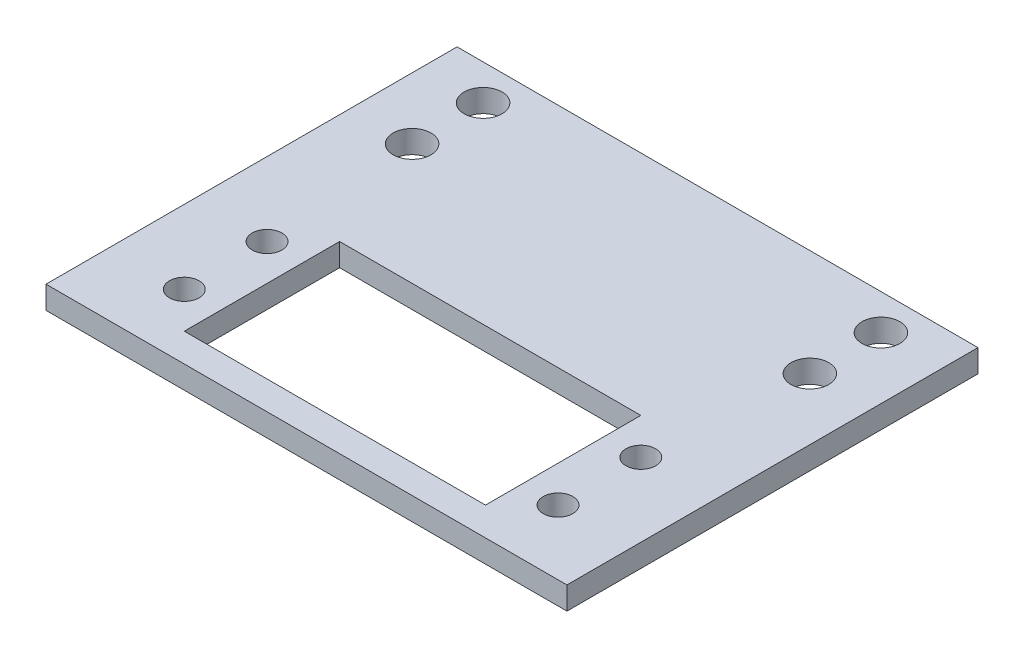
from build123d import *

# Parameters (mm, degrees)
SKETCH1_W           = 69.85
SKETCH1_H           = 55.118
SKETCH1_R           = 1.98755
SKETCH1_R_2         = 2.54
SKETCH1_W_2         = 40.386
SKETCH1_H_2         = 20.828
BOSS_EXTRUDE1_DEPTH = 3.048


with BuildPart() as part:
    # Sketch1 → Boss-Extrude1 (new body)
    with BuildSketch(Plane(origin=(0, 0, 0), x_dir=(1, 0, 0), z_dir=(0, 1, 0))):
        with Locations((0, 13.335)):
            Rectangle(SKETCH1_W, SKETCH1_H)
        with Locations((-25.0571, -5.5499)):
            Circle(SKETCH1_R, mode=Mode.SUBTRACT)
        with Locations((-25.0571, 5.5499)):
            Circle(SKETCH1_R, mode=Mode.SUBTRACT)
        with Locations((25.0571, -5.5499)):
            Circle(SKETCH1_R, mode=Mode.SUBTRACT)
        with Locations((25.0571, 5.5499)):
            Circle(SKETCH1_R, mode=Mode.SUBTRACT)
        with Locations((-26.67, 36.1315)):
            Circle(SKETCH1_R_2, mode=Mode.SUBTRACT)
        with Locations((-26.67, 26.6065)):
            Circle(SKETCH1_R_2, mode=Mode.SUBTRACT)
        with Locations((26.67, 26.6065)):
            Circle(SKETCH1_R_2, mode=Mode.SUBTRACT)
        with Locations((26.67, 36.1315)):
            Circle(SKETCH1_R_2, mode=Mode.SUBTRACT)
        Rectangle(SKETCH1_W_2, SKETCH1_H_2, mode=Mode.SUBTRACT)
    extrude(amount=BOSS_EXTRUDE1_DEPTH)


solid = part.part
